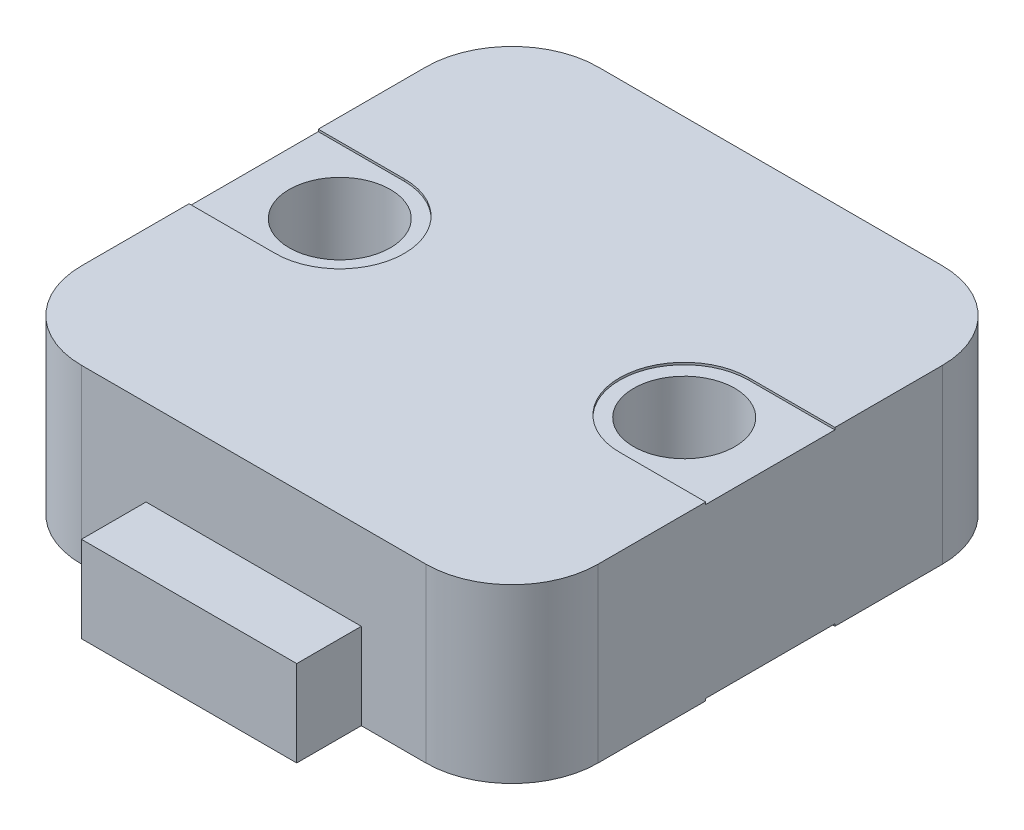
from build123d import *

# Parameters (mm, degrees)
CROQUIS1_R              = 2.35
SALIENTE_EXTRUIR1_DEPTH = 4
SALIENTE_EXTRUIR2_START = -4
CROQUIS2_W              = 10
CROQUIS2_H              = 6
SALIENTE_EXTRUIR2_DEPTH = 4
CORTAR_EXTRUIR1_DEPTH   = 0.1


with BuildPart() as part:
    # Croquis1 → Saliente-Extruir1 (new body, symmetric)
    with BuildSketch(Plane(origin=(0, 0, 0), x_dir=(1, 0, 0), z_dir=(0, 1, 0))):
        with BuildLine():
            Line((-8, 12), (8, 12))
            ThreePointArc((8, 12), (10.828427125, 10.828427125), (12, 8))
            Line((12, 8), (12, -8))
            ThreePointArc((12, -8), (10.828427125, -10.828427125), (8, -12))
            Line((8, -12), (-8, -12))
            ThreePointArc((-8, -12), (-10.828427125, -10.828427125), (-12, -8))
            Line((-12, -8), (-12, 8))
            ThreePointArc((-12, 8), (-10.828427125, 10.828427125), (-8, 12))
        make_face()
        with Locations((-8, 0)):
            Circle(CROQUIS1_R, mode=Mode.SUBTRACT)
        with Locations((8, 0)):
            Circle(CROQUIS1_R, mode=Mode.SUBTRACT)
    extrude(amount=SALIENTE_EXTRUIR1_DEPTH, both=True)

    # Croquis2 → Saliente-Extruir2 (add)
    with BuildSketch(Plane(origin=(0, 0, 0), x_dir=(1, 0, 0), z_dir=(0, 1, 0)).offset(SALIENTE_EXTRUIR2_START)):
        with Locations((0, -12)):
            Rectangle(CROQUIS2_W, CROQUIS2_H)
    extrude(amount=SALIENTE_EXTRUIR2_DEPTH)

    # Croquis3 → Cortar-Extruir1 (cut)
    with BuildSketch(Plane(origin=(0, 4, 0), x_dir=(1, 0, 0), z_dir=(0, 1, 0))):
        with BuildLine():
            Line((-8, 3), (-16.530379626, 3))
            Line((-16.530379626, 3), (-16.530379626, -3))
            Line((-16.530379626, -3), (-8, -3))
            ThreePointArc((-8, -3), (-5, 0), (-8, 3))
        make_face()
        with BuildLine():
            Line((16.530379626, -3), (8, -3))
            ThreePointArc((8, -3), (5, 0), (8, 3))
            Line((8, 3), (16.530379626, 3))
            Line((16.530379626, 3), (16.530379626, -3))
        make_face()
    cortar_extruir1 = extrude(amount=-CORTAR_EXTRUIR1_DEPTH, mode=Mode.SUBTRACT)

    # Simetría1: Cortar-Extruir1 across plane
    add(cortar_extruir1.mirror(Plane.ZX), mode=Mode.SUBTRACT)


solid = part.part
